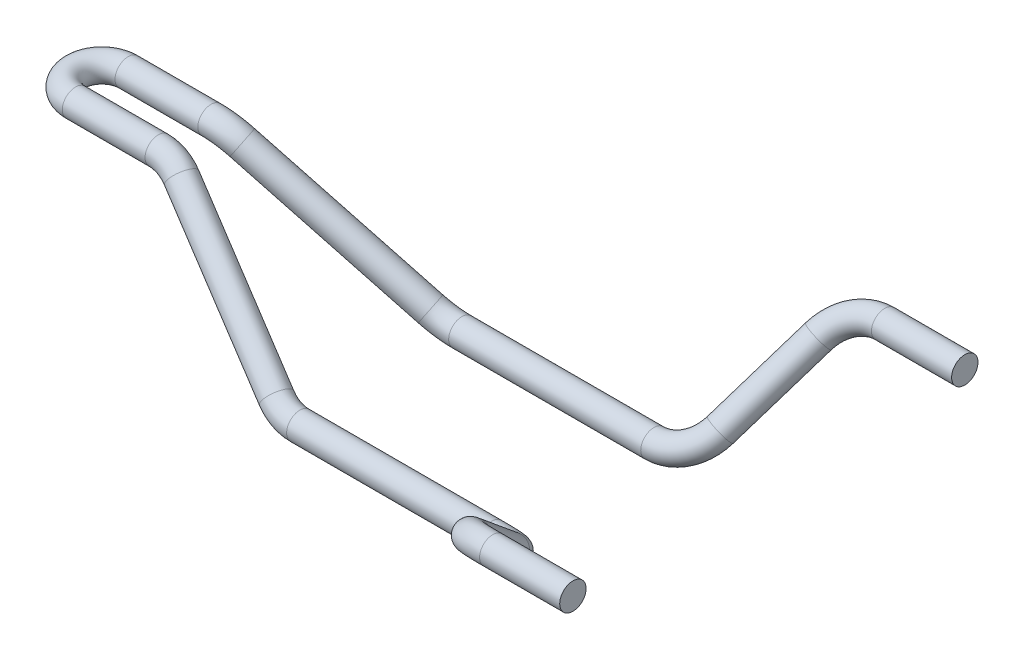
from build123d import *

# Parameters (mm, degrees)
ESQUISSE4_R = 3.5


with BuildPart() as part:
    # Balayage7: sweep along a curve in space
    with BuildLine() as balayage7_path:
        Line((177, -2.5, -52), (155.734217216, -2.5, -52))
        ThreePointArc((155.734217216, -2.5, -52), (148.672485024, -4.038717936, -50.293421925), (144.315206142, -8.065584202, -45.827261158))
        Line((144.315206142, -8.065584202, -45.827261158), (136.419011074, -24.434415798, -27.672738842))
        ThreePointArc((136.419011074, -24.434415798, -27.672738842), (132.061732193, -28.461282064, -23.206578075), (125, -30, -21.5))
        Line((125, -30, -21.5), (74.030986056, -30, -21.5))
        ThreePointArc((74.030986056, -30, -21.5), (70.209827287, -29.437603281, -21.228174919), (66.786478564, -27.808962657, -20.440998618))
        Line((66.786478564, -27.808962657, -20.440998618), (29.213521436, -2.191037343, -8.059001382))
        ThreePointArc((29.213521436, -2.191037343, -8.059001382), (25.790172713, -0.562396719, -7.271825081), (21.969013944, 0, -7))
        Line((21.969013944, 0, -7), (0, 0, -7))
        ThreePointArc((0, 0, -7), (-4.949747468, 0, -4.949747468), (-7, 0, 0))
    # Esquisse4 → Balayage7 (sweep)
    with BuildSketch(Plane.XY):
        with Locations((-7, 0)):
            Circle(ESQUISSE4_R)
    balayage7 = sweep(path=balayage7_path.line)

    # Sym_trie5: Balayage7 across plane
    add(balayage7.mirror(Plane.XY))


solid = part.part
